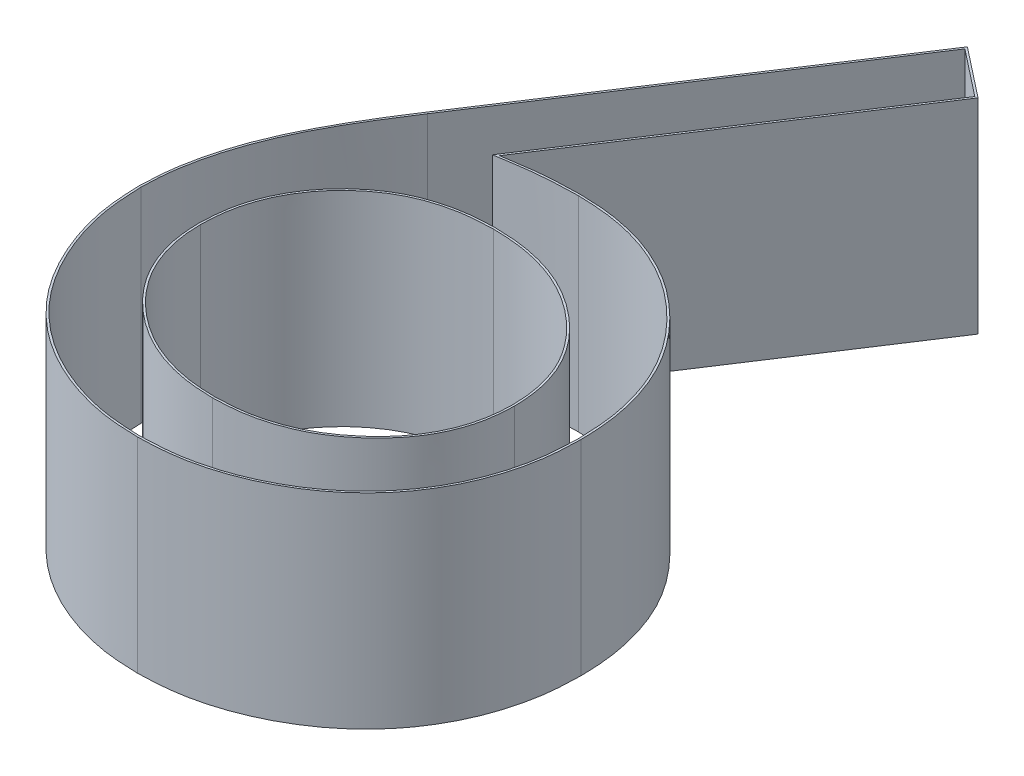
from build123d import *

# Parameters (mm, degrees)
BOSS_EXTRUDE1_DEPTH = 1
CUT_EXTRUDE1_DEPTH  = 1


with BuildPart() as part:
    # Sketch1 → Boss-Extrude1 (new body)
    with BuildSketch(Plane(origin=(0, 0, 0), x_dir=(1, 0, 0), z_dir=(0, 1, 0))):
        with BuildLine():
            Line((1.75, 3.58974359), (1.991887019, 3.399739583))
            Line((1.991887019, 3.399739583), (1.067107372, 1.985576923))
            add(Edge.make_bspline(
                [(1.067107372, 1.985576923), (1.128677649, 1.995390784), (1.248777436, 2.014533829), (1.370343334, 2.017691774), (1.42958734, 2.019230769)],
                knots=[0, 0, 0, 0, 0.000186809, 0.000364392, 0.000364392, 0.000364392, 0.000364392], degree=3))
            add(Edge.make_bspline(
                [(1.42958734, 2.019230769), (1.465159836, 2.018274658), (1.535183237, 2.01639258), (1.637990039, 2.001908729), (1.736778975, 1.979083617), (1.831140587, 1.945811362), (1.921413569, 1.903309007), (2.008115965, 1.852370137), (2.089617975, 1.790364457), (2.166969154, 1.721099501), (2.237196252, 1.644382516), (2.299372307, 1.56298118), (2.351599099, 1.476980299), (2.393973021, 1.386423433), (2.426877899, 1.291450173), (2.450865544, 1.192182034), (2.465045137, 1.088550562), (2.466970628, 1.018072387), (2.467948718, 0.982271635)],
                knots=[0, 0, 0, 0, 0.000106683, 0.000210003, 0.00031085, 0.000410412, 0.000509526, 0.000609808, 0.000711471, 0.00081622, 0.000920922, 0.001023007, 0.001123049, 0.001222163, 0.001322387, 0.001424078, 0.001528093, 0.001635477, 0.001635477, 0.001635477, 0.001635477], degree=3))
            add(Edge.make_bspline(
                [(2.467948718, 0.982271635), (2.466525613, 0.933291931), (2.463725279, 0.836911465), (2.435821483, 0.696534758), (2.392461839, 0.562802243), (2.33048431, 0.437849071), (2.253501927, 0.321846502), (2.159624335, 0.219061036), (2.052180846, 0.127390999), (1.930694048, 0.05073438), (1.799951084, -0.011868671), (1.662599087, -0.056833913), (1.51997194, -0.084517383), (1.423167332, -0.087987985), (1.374198718, -0.08974359)],
                knots=[0, 0, 0, 0, 0.000146776, 0.00028882, 0.000427614, 0.000567461, 0.000705914, 0.000843912, 0.000983689, 0.001128394, 0.001273595, 0.001417489, 0.001560911, 0.001707729, 0.001707729, 0.001707729, 0.001707729], degree=3))
            add(Edge.make_bspline(
                [(1.374198718, -0.08974359), (1.327102017, -0.088215384), (1.233811699, -0.085188276), (1.096578905, -0.058222338), (0.964715888, -0.014515235), (0.839146507, 0.045699043), (0.722825894, 0.121756926), (0.618760257, 0.213319205), (0.527468483, 0.31842867), (0.451493862, 0.437069018), (0.39123513, 0.564558975), (0.346045205, 0.697496132), (0.319648962, 0.835396113), (0.315960405, 0.928877252), (0.314102564, 0.975961538)],
                knots=[0, 0, 0, 0, 0.000141176, 0.000279646, 0.000417774, 0.000557008, 0.000696242, 0.000833365, 0.000971544, 0.001112541, 0.001254608, 0.001393623, 0.001532781, 0.001674001, 0.001674001, 0.001674001, 0.001674001], degree=3))
            add(Edge.make_bspline(
                [(0.314102564, 0.975961538), (0.315284009, 1.012006122), (0.317696294, 1.085602274), (0.334539684, 1.197066302), (0.361604479, 1.311117383), (0.391914726, 1.407871577), (0.423940336, 1.487133099), (0.450592875, 1.55103659), (0.483766871, 1.616797663), (0.519140252, 1.686671299), (0.559897121, 1.758856731), (0.604212771, 1.834560401), (0.653312422, 1.912578329), (0.687732584, 1.965522524), (0.705328526, 1.992588141)],
                knots=[0, 0, 0, 0, 0.000108118, 0.000220757, 0.000337422, 0.000459596, 0.000524434, 0.000593848, 0.000667222, 0.000745302, 0.000828791, 0.000915849, 0.00100845, 0.001105299, 0.001105299, 0.001105299, 0.001105299], degree=3))
            Line((0.705328526, 1.992588141), (1.75, 3.58974359))
        make_face()
        with BuildLine():
            add(Edge.make_bspline(
                [(1.363681891, 1.66025641), (1.337019646, 1.659478367), (1.284940537, 1.657958621), (1.208533122, 1.649133369), (1.136219871, 1.632514304), (1.067042737, 1.611347972), (1.002295034, 1.582244912), (0.941506194, 1.546893113), (0.884441142, 1.505271935), (0.831697591, 1.457971024), (0.783877927, 1.406182991), (0.742696796, 1.350713469), (0.707174396, 1.292899266), (0.678292578, 1.232257323), (0.655802502, 1.168810824), (0.639534251, 1.102851574), (0.6304805, 1.033937268), (0.628974268, 0.987204766), (0.628205128, 0.963341346)],
                knots=[0, 0, 0, 0, 8.0005e-05, 0.000156272, 0.000230267, 0.000302332, 0.000372951, 0.000442698, 0.000512957, 0.000584457, 0.000654919, 0.00072405, 0.000791387, 0.000858185, 0.000925156, 0.000993006, 0.001061623, 0.001133223, 0.001133223, 0.001133223, 0.001133223], degree=3))
            add(Edge.make_bspline(
                [(0.628205128, 0.963341346), (0.62883149, 0.939691366), (0.630059691, 0.893317277), (0.641212011, 0.824978097), (0.658247093, 0.759213189), (0.683587489, 0.69636159), (0.713814378, 0.635465272), (0.753719702, 0.578729986), (0.797936488, 0.522709916), (0.850790421, 0.471708445), (0.907513784, 0.424251821), (0.968114986, 0.382771567), (1.031274946, 0.347285394), (1.097846368, 0.319474296), (1.166884752, 0.296650009), (1.238965306, 0.28058853), (1.314138162, 0.271508004), (1.3650601, 0.26999981), (1.391025641, 0.269230769)],
                knots=[0, 0, 0, 0, 7.09e-05, 0.000139024, 0.000207221, 0.000274272, 0.000342002, 0.000410648, 0.000481932, 0.000555803, 0.000630491, 0.000703613, 0.000775798, 0.000847422, 0.000919703, 0.000993697, 0.001068572, 0.001146476, 0.001146476, 0.001146476, 0.001146476], degree=3))
            add(Edge.make_bspline(
                [(1.391025641, 0.269230769), (1.41699114, 0.269999871), (1.467912994, 0.271508182), (1.543086454, 0.280587851), (1.615164773, 0.296652499), (1.684211282, 0.31946527), (1.750752713, 0.347318879), (1.813857434, 0.382550799), (1.873885528, 0.424506917), (1.930646127, 0.471627345), (1.983280066, 0.523000197), (2.028557344, 0.578229919), (2.067240578, 0.635923815), (2.098674765, 0.696121704), (2.123736056, 0.759251192), (2.140857523, 0.824967916), (2.151986812, 0.893319942), (2.153218178, 0.939692266), (2.153846154, 0.963341346)],
                knots=[0, 0, 0, 0, 7.7903e-05, 0.000152779, 0.000226773, 0.000299053, 0.000370678, 0.000442863, 0.000515408, 0.000590096, 0.000663967, 0.000735694, 0.000803948, 0.000872001, 0.000939052, 0.001007249, 0.001075373, 0.001146273, 0.001146273, 0.001146273, 0.001146273], degree=3))
            add(Edge.make_bspline(
                [(2.153846154, 0.963341346), (2.153295861, 0.987235897), (2.152215815, 1.03413313), (2.139999866, 1.102820748), (2.123057492, 1.169145954), (2.097474462, 1.232691903), (2.064237917, 1.29320783), (2.02375451, 1.350999431), (1.976921939, 1.406509779), (1.9228244, 1.458072587), (1.863934166, 1.505219665), (1.801318581, 1.546839221), (1.735810607, 1.581964198), (1.667476664, 1.6112713), (1.595533782, 1.632420774), (1.521143443, 1.649074017), (1.4433542, 1.657936035), (1.390577592, 1.6594731), (1.363681891, 1.66025641)],
                knots=[0, 0, 0, 0, 7.16e-05, 0.000140528, 0.000208725, 0.000276686, 0.0003454, 0.000415417, 0.000488044, 0.000562919, 0.000639239, 0.000714104, 0.000788135, 0.00086197, 0.000936714, 0.001012762, 0.001090422, 0.001171127, 0.001171127, 0.001171127, 0.001171127], degree=3))
        make_face(mode=Mode.SUBTRACT)
    extrude(amount=BOSS_EXTRUDE1_DEPTH)

    # Sketch2 → Cut-Extrude1 (cut)
    with BuildSketch(Plane(origin=(0, 1, 0), x_dir=(1, 0, 0), z_dir=(0, 1, 0))):
        with BuildLine():
            Line((1.752399086, 3.575142874), (0.713704922, 1.987125891))
            add(Edge.make_bspline(
                [(0.713704922, 1.987125891), (0.613425143, 1.832878155), (0.514631885, 1.676819902), (0.407415778, 1.422117536), (0.377751623, 1.335710812), (0.346846368, 1.203207544), (0.338430115, 1.158622086), (0.327380824, 1.068169992), (0.325620587, 1.022110001), (0.324109029, 0.975994918)],
                knots=[0, 0, 0, 0, 0.5, 0.5, 0.75, 0.75, 0.875, 0.875, 1, 1, 1, 1], degree=3))
            add(Edge.make_bspline(
                [(0.324109029, 0.975994918), (0.326837937, 0.906835533), (0.330478854, 0.837848066), (0.355711549, 0.703256987), (0.375711174, 0.63719383), (0.453567064, 0.443355244), (0.52610732, 0.326325844), (0.721671106, 0.12716323), (0.838953866, 0.050541008), (1.031589506, -0.027714776), (1.097670218, -0.047635062), (1.233929294, -0.073958129), (1.304311324, -0.077470569), (1.374181711, -0.079737775)],
                knots=[0, 0, 0, 0, 0.125, 0.125, 0.25, 0.25, 0.5, 0.5, 0.75, 0.75, 0.875, 0.875, 1, 1, 1, 1], degree=3))
            add(Edge.make_bspline(
                [(1.374181711, -0.079737775), (1.444856478, -0.077203939), (1.515352362, -0.073687267), (1.653000612, -0.048283654), (1.720799138, -0.028825857), (1.919381181, 0.049039815), (2.039261006, 0.122734955), (2.245922983, 0.318459442), (2.326425948, 0.436546935), (2.406575448, 0.632875125), (2.426121789, 0.700448161), (2.452557007, 0.839354854), (2.455876016, 0.91108044), (2.45794475, 0.982280304)],
                knots=[0, 0, 0, 0, 0.125, 0.125, 0.25, 0.25, 0.5, 0.5, 0.75, 0.75, 0.875, 0.875, 1, 1, 1, 1], degree=3))
            add(Edge.make_bspline(
                [(2.45794475, 0.982280304), (2.456093691, 1.050033131), (2.452534146, 1.117497043), (2.428528934, 1.24956933), (2.40990041, 1.315143272), (2.334253841, 1.503970367), (2.256541009, 1.615494688), (2.112738626, 1.758480193), (2.061245449, 1.801793205), (1.949478126, 1.877689709), (1.888655774, 1.909603996), (1.76429285, 1.960608852), (1.699563645, 1.979007129), (1.565668993, 2.003433622), (1.497611682, 2.007398787), (1.429582838, 2.009227279)],
                knots=[0, 0, 0, 0, 0.125, 0.125, 0.25, 0.25, 0.5, 0.5, 0.625, 0.625, 0.75, 0.75, 0.875, 0.875, 1, 1, 1, 1], degree=3))
            add(Edge.make_bspline(
                [(1.429582838, 2.009227279), (1.399078585, 2.008434858), (1.368571343, 2.007641674), (1.307591553, 2.005006801), (1.277104184, 2.003158597), (1.213172773, 1.997069447), (1.179738406, 1.992676283), (1.113012867, 1.982859491), (1.079700675, 1.977457972), (1.046376129, 1.972146278)],
                knots=[0, 0, 0, 0, 9.1544e-05, 9.1544e-05, 0.000183128, 0.000183128, 0.000284245, 0.000284245, 0.000385481, 0.000385481, 0.000385481, 0.000385481], degree=3))
            Line((1.046376129, 1.972146278), (1.978499708, 3.397539197))
            Line((1.978499708, 3.397539197), (1.752399086, 3.575142874))
        make_face()
        with BuildLine():
            add(Edge.make_bspline(
                [(0.618200861, 0.963370065), (0.619489439, 0.914716284), (0.623076246, 0.866471918), (0.643412028, 0.772327939), (0.659680702, 0.725792757), (0.721264037, 0.593846029), (0.784280071, 0.517250476), (0.930257515, 0.39036451), (1.015015297, 0.339513262), (1.150814272, 0.290711998), (1.198046211, 0.278194663), (1.293942933, 0.26287819), (1.34244494, 0.260665236), (1.391025653, 0.259226384)],
                knots=[0, 0, 0, 0, 0.125, 0.125, 0.25, 0.25, 0.5, 0.5, 0.75, 0.75, 0.875, 0.875, 1, 1, 1, 1], degree=3))
            add(Edge.make_bspline(
                [(1.391025653, 0.259226384), (1.43980601, 0.260671264), (1.488421162, 0.262933678), (1.583499434, 0.278108135), (1.630101106, 0.29033453), (1.721613544, 0.323154997), (1.766695284, 0.343738856), (1.849374734, 0.39358807), (1.88794735, 0.422403392), (1.997459319, 0.51757518), (2.059654132, 0.594246302), (2.122585885, 0.725243916), (2.13853311, 0.772054847), (2.158979567, 0.866296287), (2.162555563, 0.914605904), (2.163849211, 0.963323732)],
                knots=[0, 0, 0, 0, 0.125, 0.125, 0.25, 0.25, 0.375, 0.375, 0.5, 0.5, 0.75, 0.75, 0.875, 0.875, 1, 1, 1, 1], degree=3))
            add(Edge.make_bspline(
                [(2.163849211, 0.963323732), (2.162700748, 1.01319175), (2.158399366, 1.062528155), (2.136845478, 1.159017284), (2.1204952, 1.206931223), (2.053426709, 1.338933605), (1.987569492, 1.416231793), (1.836244751, 1.541928542), (1.749004751, 1.593227323), (1.609135896, 1.639912362), (1.560672931, 1.651838628), (1.462733794, 1.666822095), (1.413234319, 1.668817486), (1.363681604, 1.670260659)],
                knots=[0, 0, 0, 0, 0.125, 0.125, 0.25, 0.25, 0.5, 0.5, 0.75, 0.75, 0.875, 0.875, 1, 1, 1, 1], degree=3))
            add(Edge.make_bspline(
                [(1.363681604, 1.670260659), (1.315723013, 1.668861156), (1.267851811, 1.666962674), (1.173935486, 1.652738983), (1.127735015, 1.641300796), (0.991259638, 1.594846782), (0.908598911, 1.54269672), (0.768334766, 1.410929019), (0.711155485, 1.331235398), (0.654734266, 1.199989987), (0.640619096, 1.154558898), (0.622378007, 1.060114356), (0.619755856, 1.011615494), (0.618200861, 0.963370065)],
                knots=[0, 0, 0, 0, 0.125, 0.125, 0.25, 0.25, 0.5, 0.5, 0.75, 0.75, 0.875, 0.875, 1, 1, 1, 1], degree=3))
        make_face(mode=Mode.SUBTRACT)
    extrude(amount=-CUT_EXTRUDE1_DEPTH, mode=Mode.SUBTRACT)


solid = part.part
